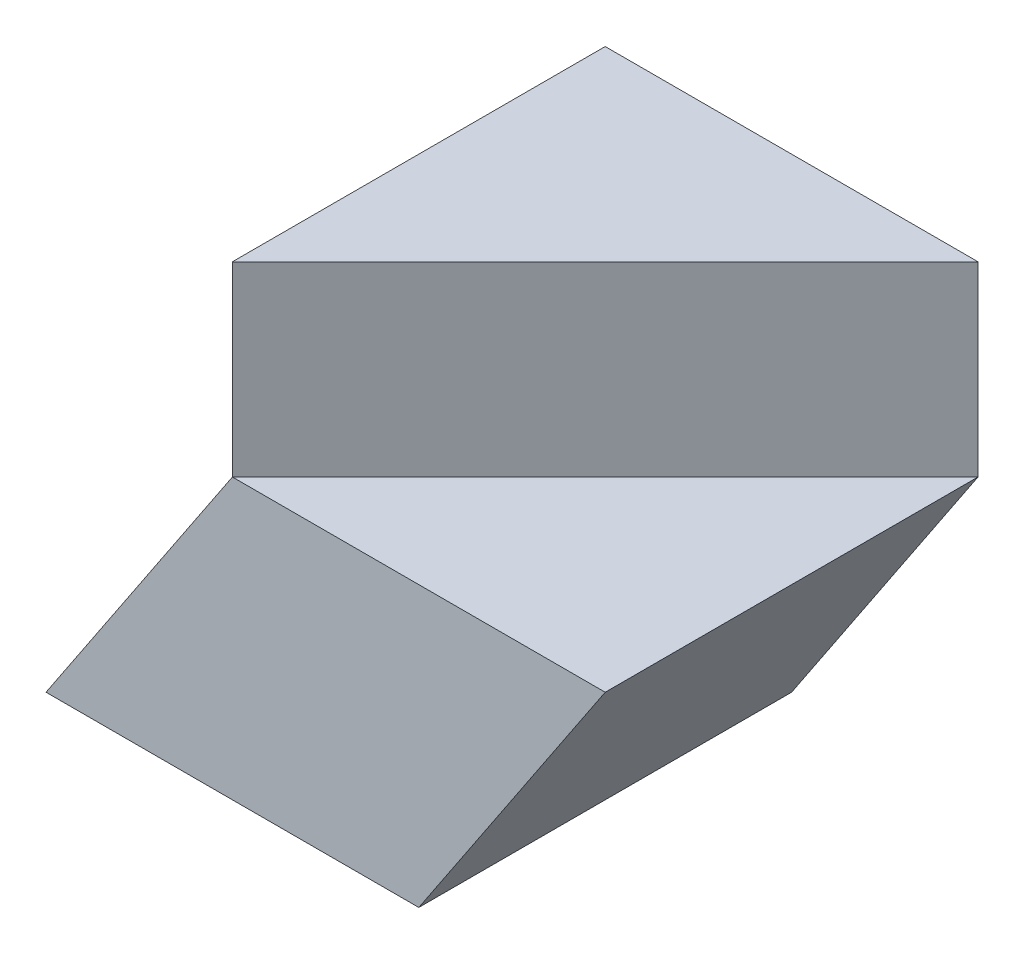
from build123d import *

# Parameters (mm, degrees)
SKETCH1_W           = 40
SKETCH1_H           = 20
BOSS_EXTRUDE1_DEPTH = 40
CUT_EXTRUDE1_DEPTH  = 20


with BuildPart() as part:
    # Sketch1 → Boss-Extrude1 (new body)
    with BuildSketch(Plane.XY):
        Polygon((20, -30), (-20, -30), (0, 0), (40, 0), align=None)
        with Locations((20, 10)):
            Rectangle(SKETCH1_W, SKETCH1_H)
    extrude(amount=BOSS_EXTRUDE1_DEPTH)

    # Sketch2 → Cut-Extrude1 (cut)
    with BuildSketch(Plane(origin=(0, 20, 0), x_dir=(1, 0, 0), z_dir=(0, 1, 0))):
        Polygon((0, -40), (40, 0), (40, -40), align=None)
    extrude(amount=-CUT_EXTRUDE1_DEPTH, mode=Mode.SUBTRACT)


solid = part.part
